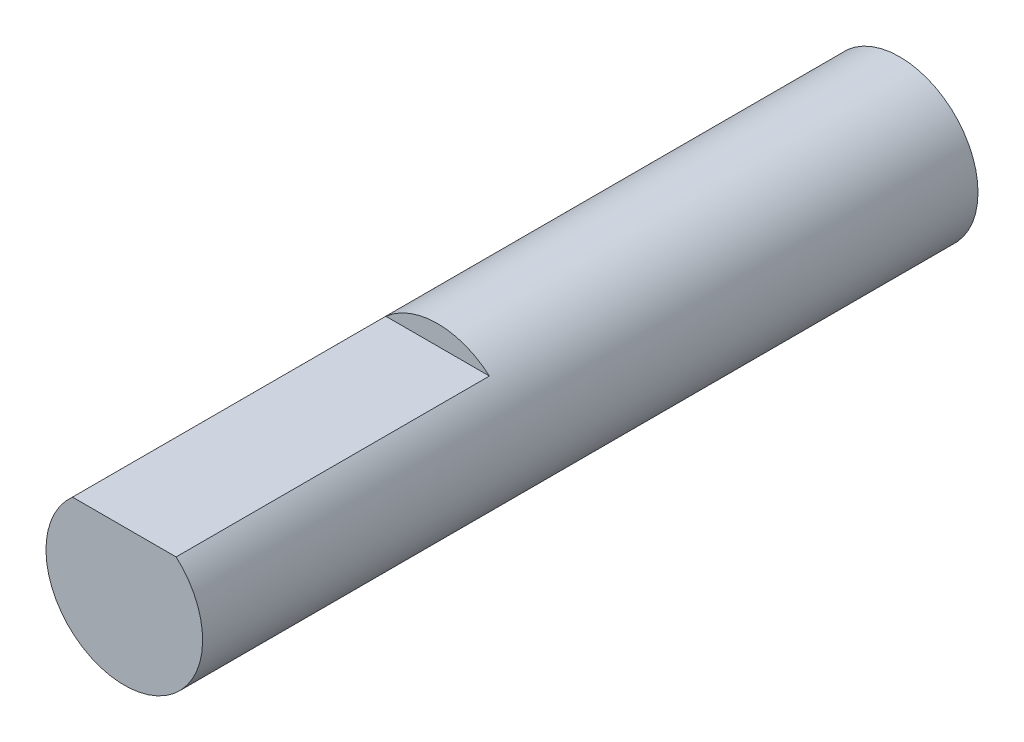
from build123d import *

# Parameters (mm, degrees)
SKETCH1_R               = 2
BOSS_EXTRUDE1_DEPTH     = 19.8
CUT_EXTRUDE1_DEPTH      = 1
CUT_EXTRUDE1_DEPTH_BACK = 8


with BuildPart() as part:
    # Sketch1 → Boss-Extrude1 (new body)
    with BuildSketch(Plane.XY):
        Circle(SKETCH1_R)
    extrude(amount=BOSS_EXTRUDE1_DEPTH)

    # Sketch2 → Cut-Extrude1 (cut, two sides)
    with BuildSketch(Plane.XY.offset(19.8)) as cut_extrude1_sk:
        Polygon((-20.975129822, 1.5), (-1.322875656, 1.5), (1.322875656, 1.5), (20.975129822, 1.5), (20.975129822, 40.804508332), (-20.975129822, 40.804508332), align=None)
    extrude(amount=CUT_EXTRUDE1_DEPTH, mode=Mode.SUBTRACT)
    extrude(cut_extrude1_sk.sketch, amount=-CUT_EXTRUDE1_DEPTH_BACK, mode=Mode.SUBTRACT)


solid = part.part
